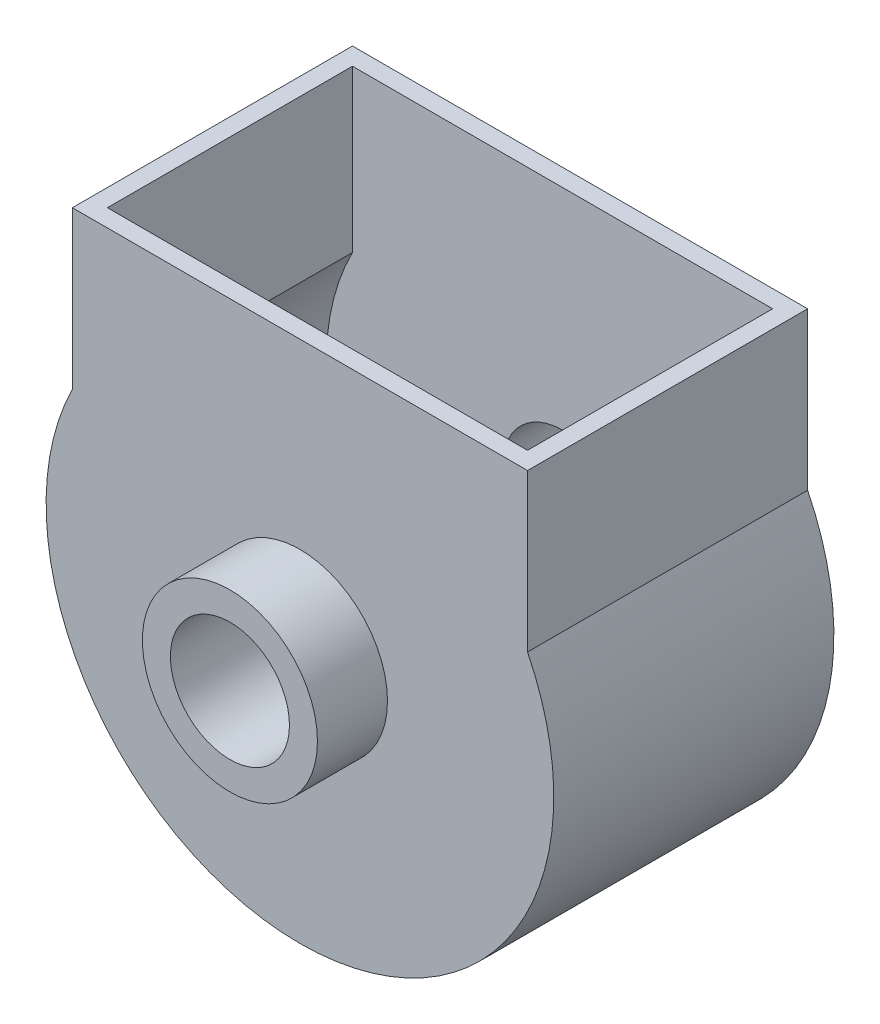
from build123d import *

# Parameters (mm, degrees)
SKETCH1_R                = 250
SKETCH1_R_2              = 170
BOSS_EXTRUDE1_DEPTH      = 200
BOSS_EXTRUDE1_DEPTH_BACK = 50
SKETCH2_R                = 250
BOSS_EXTRUDE3_DEPTH      = 50
BOSS_EXTRUDE4_START      = -350
BOSS_EXTRUDE4_DEPTH      = 700


with BuildPart() as part:
    # Sketch1 → Boss-Extrude1 (new body, two sides)
    with BuildSketch(Plane.XY) as boss_extrude1_sk:
        Circle(SKETCH1_R)
        Circle(SKETCH1_R_2, mode=Mode.SUBTRACT)
    extrude(amount=BOSS_EXTRUDE1_DEPTH)
    extrude(boss_extrude1_sk.sketch, amount=-BOSS_EXTRUDE1_DEPTH_BACK)

    # Sketch2 → Boss-Extrude3 (add)
    with BuildSketch(Plane.XY):
        with BuildLine():
            Line((-650, 770), (-650, 321.130814467))
            ThreePointArc((-650, 321.130814467), (0, -725), (650, 321.130814467))
            Line((650, 321.130814467), (650, 770))
            Line((650, 770), (-650, 770))
        make_face()
        Circle(SKETCH2_R, mode=Mode.SUBTRACT)
    extrude(amount=-BOSS_EXTRUDE3_DEPTH)


with BuildPart() as body_2:
    # Mirror9: mirrored copy
    add(part.part.mirror(Plane.XY.offset(-400)))


with BuildPart() as part_1:
    add(part.part)

    add(body_2.part)  # Boss-Extrude4 merges body 2
    # Sketch4 → Boss-Extrude4 (add)
    with BuildSketch(Plane.XY.offset(-400).offset(BOSS_EXTRUDE4_START)):
        with BuildLine():
            Line((-600, 770), (-600, 309.232921921))
            ThreePointArc((-600, 309.232921921), (0, -675), (600, 309.232921921))
            Line((600, 309.232921921), (600, 770))
            Line((600, 770), (650, 770))
            Line((650, 770), (650, 321.130814467))
            ThreePointArc((650, 321.130814467), (0, -725), (-650, 321.130814467))
            Line((-650, 321.130814467), (-650, 770))
            Line((-650, 770), (-600, 770))
        make_face()
    extrude(amount=BOSS_EXTRUDE4_DEPTH)


solid = part_1.part
